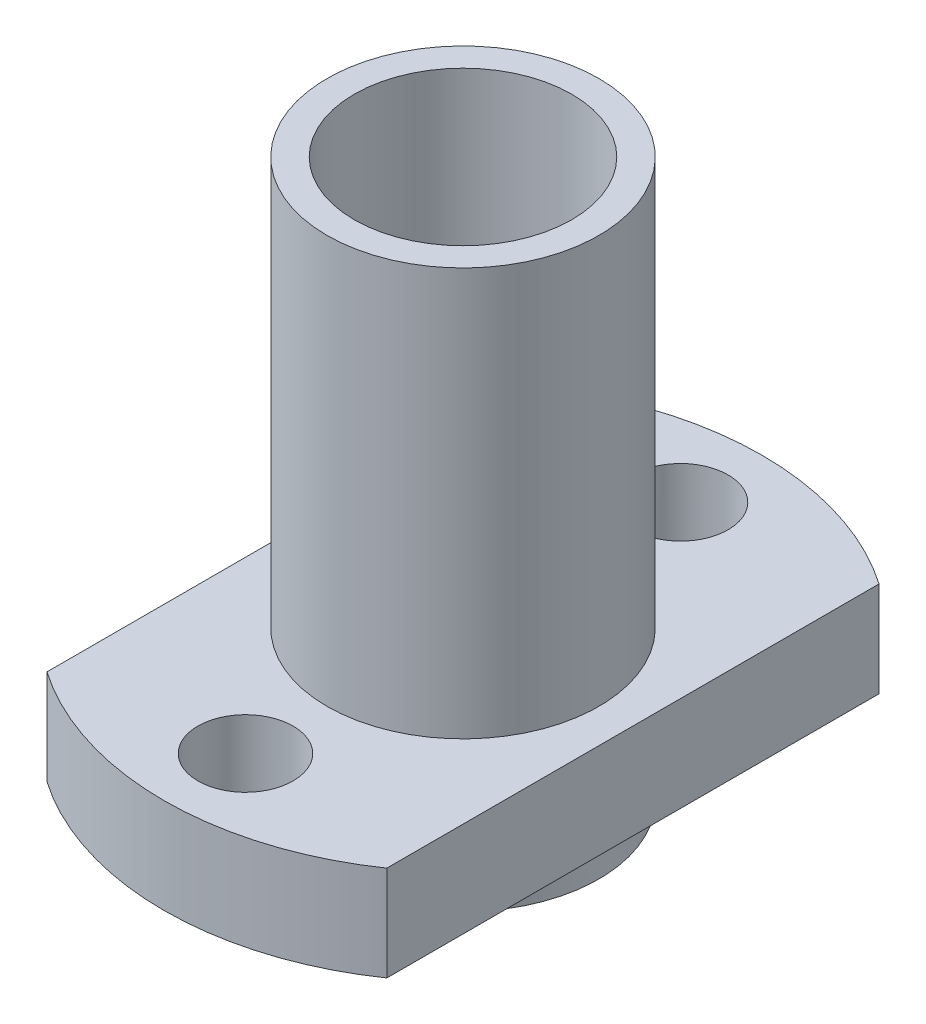
from build123d import *

# Parameters (mm, degrees)
SKETCH_1_R           = 11
EXTRUDE_1_DEPTH      = 3.5
SKETCH_2_R           = 5
SKETCH_2_R_2         = 4
EXTRUDE_2_DEPTH      = 15
EXTRUDE_2_DEPTH_BACK = 5.5
SKETCH_3_R           = 4
SKETCH_3_R_2         = 1.75
CUT_EXTRUDE_1_DEPTH  = 6.5
CUT_EXTRUDE_2_DEPTH  = 10


with BuildPart() as part:
    # 草图1 → 凸台-拉伸1 (new body)
    with BuildSketch(Plane.XZ.offset(-1.5)):
        Circle(SKETCH_1_R)
    extrude(amount=-EXTRUDE_1_DEPTH)

    # 草图2 → 凸台-拉伸2 (add, two sides)
    with BuildSketch(Plane(origin=(0, 5, 0), x_dir=(1, 0, 0), z_dir=(0, 1, 0))) as extrude_2_sk:
        Circle(SKETCH_2_R)
        Circle(SKETCH_2_R_2, mode=Mode.SUBTRACT)
    extrude(amount=EXTRUDE_2_DEPTH)
    extrude(extrude_2_sk.sketch, amount=-EXTRUDE_2_DEPTH_BACK)

    # 草图3 → 切除-拉伸1 (cut, through all)
    with BuildSketch(Plane(origin=(0, 5, 0), x_dir=(1, 0, 0), z_dir=(0, 1, 0))):
        Circle(SKETCH_3_R)
        with Locations((-8, 0)):
            Circle(SKETCH_3_R_2)
        with Locations((0, 8)):
            Circle(SKETCH_3_R_2)
        with Locations((8, 0)):
            Circle(SKETCH_3_R_2)
        with Locations((0, -8)):
            Circle(SKETCH_3_R_2)
    extrude(amount=-CUT_EXTRUDE_1_DEPTH, mode=Mode.SUBTRACT)

    # 草图4 → 切除-拉伸2 (cut)
    with BuildSketch(Plane.XZ.offset(-1.5)):
        with BuildLine():
            Line((-6.25, -9.051933495), (-6.25, 9.051933495))
            ThreePointArc((-6.25, 9.051933495), (-11, 0), (-6.25, -9.051933495))
        make_face()
        with BuildLine():
            Line((6.25, 9.051933495), (6.25, -9.051933495))
            ThreePointArc((6.25, -9.051933495), (11, 0), (6.25, 9.051933495))
        make_face()
    extrude(amount=-CUT_EXTRUDE_2_DEPTH, mode=Mode.SUBTRACT)


solid = part.part
